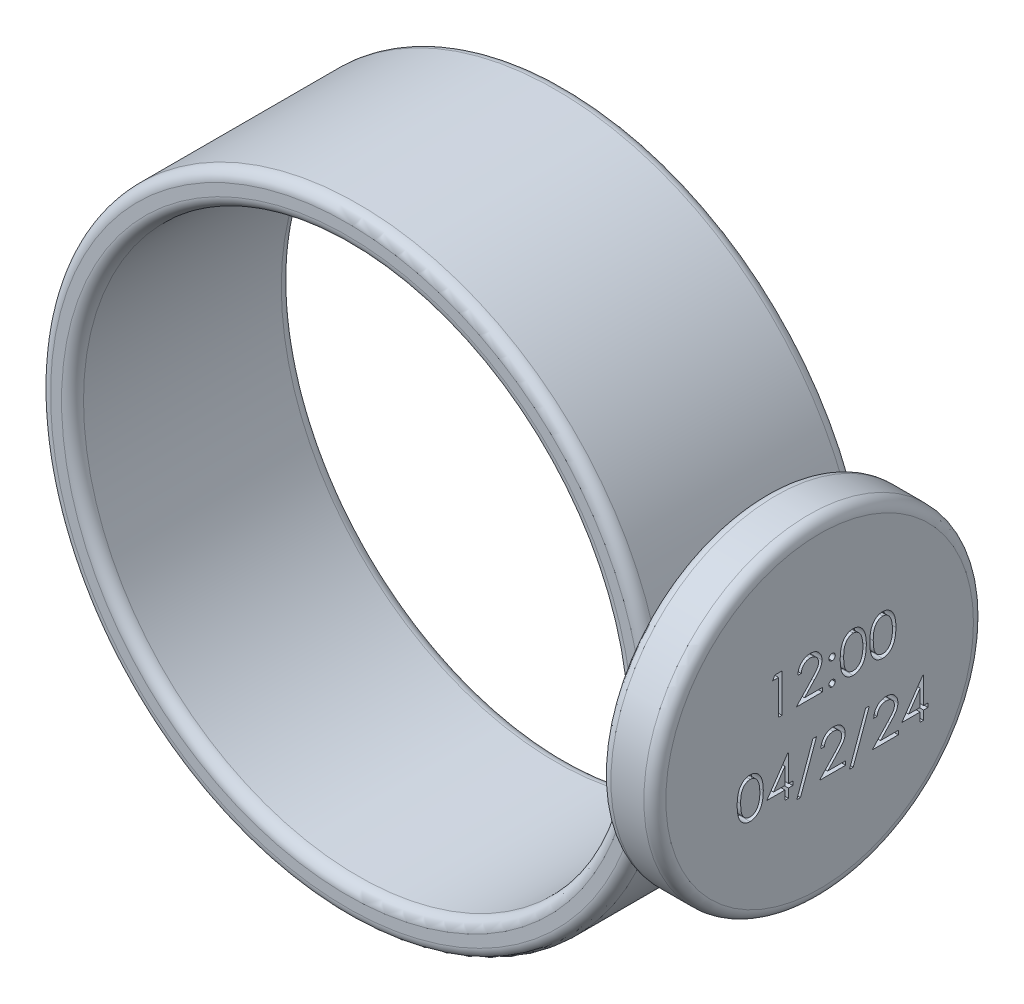
from build123d import *

# Parameters (mm, degrees)
SKETCH1_R           = 28
SKETCH1_R_2         = 25
BOSS_EXTRUDE1_DEPTH = 20
SKETCH2_R           = 15
BOSS_EXTRUDE2_DEPTH = 5
FILLET1_R           = 1
FILLET5_R           = 1
CUT_EXTRUDE3_DEPTH  = 1


with BuildPart() as part:
    # Sketch1 → Boss-Extrude1 (new body)
    with BuildSketch(Plane.XY):
        Circle(SKETCH1_R)
        Circle(SKETCH1_R_2, mode=Mode.SUBTRACT)
    extrude(amount=BOSS_EXTRUDE1_DEPTH)

    # Fillet5
    fillet5_edges = [part.edges().sort_by_distance(p)[0] for p in [
        (-28, 0, 0),
        (-28, 0, 20),
        (-25, 0, 0),
        (-25, 0, 20),
    ]]
    fillet(fillet5_edges, radius=FILLET5_R)


with BuildPart() as body_2:
    # Sketch2 → Boss-Extrude2 (new body)
    with BuildSketch(Plane(origin=(28, 0, 0), x_dir=(0, 0, -1), z_dir=(1, 0, 0))):
        with Locations((-10, 0)):
            Circle(SKETCH2_R)
    extrude(amount=BOSS_EXTRUDE2_DEPTH)

    # Fillet1
    fillet1_edges = [body_2.edges().sort_by_distance(p)[0] for p in [
        (28, 0, 25),
        (33, 0, 25),
    ]]
    fillet(fillet1_edges, radius=FILLET1_R)

    # Sketch5 → Cut-Extrude3 (cut)
    with BuildSketch(Plane(origin=(33, 0, 0), x_dir=(0, 0, -1), z_dir=(1, 0, 0))):
        Polygon((-14.07079668, 4.898543841), (-13.423661263, 4.898543841), (-13.423661263, 1.398543841), (-13.737763827, 1.398543841), (-13.737763827, 4.539569482), (-14.276225365, 4.539569482), align=None)
        with BuildLine():
            Line((-11.673661263, 3.821620764), (-11.987763827, 3.821620764))
            add(Edge.make_bspline(
                [(-11.987763827, 3.821620764), (-11.985716674, 3.863291652), (-11.98169612, 3.945132167), (-11.962867831, 4.064456073), (-11.935926954, 4.178510872), (-11.897835499, 4.286380786), (-11.850529222, 4.389019593), (-11.793799194, 4.486019609), (-11.726605344, 4.577010797), (-11.65039861, 4.661149641), (-11.567629971, 4.738337212), (-11.478324031, 4.804992454), (-11.384479004, 4.861310126), (-11.286379605, 4.908391368), (-11.182919041, 4.943731213), (-11.075036184, 4.969952853), (-10.962257047, 4.985729199), (-10.885417025, 4.987424984), (-10.846337545, 4.988287431)],
                knots=[0, 0, 0, 0, 1.10065271, 2.161652631, 3.183658789, 4.190468796, 5.17591951, 6.163126047, 7.15150782, 8.156236427, 9.156009102, 10.134482811, 11.092018607, 12.041330605, 13.001268258, 13.972401359, 14.968799086, 16, 16, 16, 16], degree=3))
            add(Edge.make_bspline(
                [(-10.846337545, 4.988287431), (-10.807959471, 4.987388975), (-10.732547926, 4.98562354), (-10.622485912, 4.97046251), (-10.517708617, 4.946716919), (-10.418420851, 4.913401503), (-10.325414786, 4.868617075), (-10.237991742, 4.814819536), (-10.155110931, 4.752599705), (-10.080504147, 4.679345892), (-10.011996068, 4.601143507), (-9.952893813, 4.517655604), (-9.902280649, 4.431426318), (-9.86009297, 4.341798116), (-9.829036831, 4.247927088), (-9.805458623, 4.151179885), (-9.792131209, 4.050555074), (-9.790085785, 3.982448518), (-9.789045878, 3.947822687)],
                knots=[0, 0, 0, 0, 1.111607364, 2.184268762, 3.212621178, 4.221274766, 5.211760367, 6.196651075, 7.1921475, 8.207485113, 9.220403448, 10.201281604, 11.166441695, 12.114753415, 13.065576456, 14.026450734, 14.996634279, 16, 16, 16, 16], degree=3))
            add(Edge.make_bspline(
                [(-9.789045878, 3.947822687), (-9.790739141, 3.899074853), (-9.794095952, 3.802434639), (-9.822810329, 3.660419776), (-9.86765684, 3.522826357), (-9.921654197, 3.412089055), (-9.976126641, 3.322855561), (-10.025214149, 3.249386857), (-10.08267896, 3.170281388), (-10.149357458, 3.085804051), (-10.22387033, 2.995293146), (-10.306892493, 2.89880335), (-10.399015975, 2.79733158), (-10.463674476, 2.728025979), (-10.497178891, 2.692113553)],
                knots=[0, 0, 0, 0, 1.184426356, 2.348067706, 3.509069118, 4.696110526, 5.333549288, 6.050745305, 6.844228056, 7.710549037, 8.667450064, 9.695053472, 10.805634456, 12, 12, 12, 12], degree=3))
            Line((-10.497178891, 2.692113553), (-11.372880013, 1.7575182))
            Line((-11.372880013, 1.7575182), (-9.744174083, 1.7575182))
            Line((-9.744174083, 1.7575182), (-9.744174083, 1.398543841))
            Line((-9.744174083, 1.398543841), (-12.122379212, 1.398543841))
            Line((-12.122379212, 1.398543841), (-10.765007417, 2.847061469))
            add(Edge.make_bspline(
                [(-10.765007417, 2.847061469), (-10.73195953, 2.881559776), (-10.668481303, 2.947823963), (-10.578698726, 3.044566923), (-10.498059738, 3.134316464), (-10.426042345, 3.216903012), (-10.36420884, 3.29353458), (-10.309336608, 3.361729283), (-10.265371017, 3.424483734), (-10.217655621, 3.497224348), (-10.17144164, 3.586036665), (-10.131729284, 3.694570354), (-10.107514435, 3.806297607), (-10.1046096, 3.881799644), (-10.103148442, 3.919777816)],
                knots=[0, 0, 0, 0, 1.329631726, 2.553950428, 3.673215718, 4.687767853, 5.603093632, 6.413772471, 7.123043292, 7.734684054, 8.834405432, 9.900288307, 10.943827018, 12, 12, 12, 12], degree=3))
            add(Edge.make_bspline(
                [(-10.103148442, 3.919777816), (-10.103784185, 3.943659214), (-10.105037111, 3.990724864), (-10.116094808, 4.059730623), (-10.132805314, 4.126295437), (-10.156750572, 4.190624056), (-10.188357312, 4.252069708), (-10.226830692, 4.310707189), (-10.271220756, 4.367396154), (-10.322572025, 4.420549452), (-10.378983545, 4.469230657), (-10.438577794, 4.512354743), (-10.501627899, 4.548393854), (-10.567868021, 4.577937351), (-10.63711349, 4.601112732), (-10.709498235, 4.617171311), (-10.784822252, 4.627253795), (-10.836255747, 4.628617967), (-10.862463346, 4.629313072)],
                knots=[0, 0, 0, 0, 0.991446411, 1.95395049, 2.89581595, 3.838931463, 4.798493298, 5.75982156, 6.748411868, 7.785213223, 8.824556874, 9.840280684, 10.836137867, 11.835679398, 12.848801643, 13.863922112, 14.911575587, 16, 16, 16, 16], degree=3))
            add(Edge.make_bspline(
                [(-10.862463346, 4.629313072), (-10.889834179, 4.62859804), (-10.943585975, 4.627193834), (-11.022505008, 4.61737117), (-11.097790786, 4.60042533), (-11.169632689, 4.577248656), (-11.238152274, 4.547790107), (-11.303016318, 4.511098362), (-11.364079208, 4.467314869), (-11.421455731, 4.417674313), (-11.47431971, 4.362406711), (-11.520766586, 4.300796748), (-11.5613506, 4.233969333), (-11.596759834, 4.162104782), (-11.625515524, 4.084551003), (-11.647488674, 4.001583298), (-11.664875521, 3.913561916), (-11.670684041, 3.852776831), (-11.673661263, 3.821620764)],
                knots=[0, 0, 0, 0, 1.031018746, 2.02475058, 2.990194455, 3.934040569, 4.864654155, 5.795059489, 6.735614925, 7.690564532, 8.649604399, 9.611025574, 10.590972636, 11.591080095, 12.624614302, 13.701020113, 14.821632451, 16, 16, 16, 16], degree=3))
        make_face()
        with BuildLine():
            add(Edge.make_bspline(
                [(-8.869174083, 4.001107944), (-8.849683871, 3.999949777), (-8.811475589, 3.997679327), (-8.756236461, 3.982102653), (-8.706241801, 3.954443993), (-8.661709556, 3.917581214), (-8.62500308, 3.872885551), (-8.596358727, 3.823289642), (-8.580917742, 3.76758805), (-8.57866383, 3.729158375), (-8.577507417, 3.709441277)],
                knots=[0, 0, 0, 0, 1.020151414, 1.999887582, 2.974338812, 3.990962822, 5.007586832, 5.987933904, 6.967670073, 8, 8, 8, 8], degree=3))
            add(Edge.make_bspline(
                [(-8.577507417, 3.709441277), (-8.57866383, 3.68972418), (-8.580917742, 3.651294505), (-8.596358727, 3.595592912), (-8.62500308, 3.545997003), (-8.661709556, 3.50130134), (-8.706241801, 3.464438562), (-8.756236461, 3.436779901), (-8.811475589, 3.421203228), (-8.849683871, 3.418932777), (-8.869174083, 3.41777461)],
                knots=[0, 0, 0, 0, 1.032329927, 2.012066096, 2.992413168, 4.009037178, 5.025661188, 6.000112418, 6.979848586, 8, 8, 8, 8], degree=3))
            add(Edge.make_bspline(
                [(-8.869174083, 3.41777461), (-8.888677785, 3.418894506), (-8.926687724, 3.421077023), (-8.981727264, 3.437117435), (-9.032023469, 3.464182228), (-9.076547765, 3.501369531), (-9.11355316, 3.545766111), (-9.140929372, 3.59593455), (-9.157705032, 3.651133658), (-9.159778651, 3.689691898), (-9.16084075, 3.709441277)],
                knots=[0, 0, 0, 0, 1.020591893, 1.988988293, 2.974634352, 3.991697318, 5.008760285, 5.983632262, 6.967224335, 8, 8, 8, 8], degree=3))
            add(Edge.make_bspline(
                [(-9.16084075, 3.709441277), (-9.159739929, 3.72871909), (-9.157565378, 3.766800281), (-9.14092151, 3.821533677), (-9.113587869, 3.871759072), (-9.076313445, 3.916050593), (-9.032292504, 3.954132893), (-8.981567818, 3.980822161), (-8.92682963, 3.998038024), (-8.888703362, 4.00006809), (-8.869174083, 4.001107944)],
                knots=[0, 0, 0, 0, 1.010056097, 1.99525427, 2.971718109, 3.990441831, 5.01702829, 6.004283803, 6.977741589, 8, 8, 8, 8], degree=3))
        make_face()
        with BuildLine():
            add(Edge.make_bspline(
                [(-8.869174083, 1.93700538), (-8.849683871, 1.935847213), (-8.811475589, 1.933576763), (-8.756236461, 1.918000089), (-8.706241801, 1.890341428), (-8.661709556, 1.85347865), (-8.62500308, 1.808782987), (-8.596358727, 1.759187078), (-8.580917742, 1.703485486), (-8.57866383, 1.665055811), (-8.577507417, 1.645338713)],
                knots=[0, 0, 0, 0, 1.020151414, 1.999887582, 2.974338812, 3.990962822, 5.007586832, 5.987933904, 6.967670073, 8, 8, 8, 8], degree=3))
            add(Edge.make_bspline(
                [(-8.577507417, 1.645338713), (-8.578703017, 1.626095383), (-8.581060725, 1.58814782), (-8.596323333, 1.532866357), (-8.625221383, 1.483239453), (-8.661456376, 1.437937314), (-8.706252809, 1.400996444), (-8.756354656, 1.373573099), (-8.811345914, 1.356881119), (-8.849662237, 1.354754822), (-8.869174083, 1.353672046)],
                knots=[0, 0, 0, 0, 1.009421747, 1.99056486, 2.972319754, 3.999869655, 5.017953583, 5.993804169, 6.978383603, 8, 8, 8, 8], degree=3))
            add(Edge.make_bspline(
                [(-8.869174083, 1.353672046), (-8.888699989, 1.354715644), (-8.926819672, 1.356753019), (-8.981605666, 1.373915825), (-9.032012634, 1.400739285), (-9.076800346, 1.438006195), (-9.113338818, 1.483006338), (-9.140964201, 1.533208134), (-9.15755435, 1.587989572), (-9.159736222, 1.626064215), (-9.16084075, 1.645338713)],
                knots=[0, 0, 0, 0, 1.022052826, 1.995314843, 2.982371812, 4.00089066, 5.028879526, 6.005146991, 6.990147033, 8, 8, 8, 8], degree=3))
            add(Edge.make_bspline(
                [(-9.16084075, 1.645338713), (-9.159778651, 1.665088093), (-9.157705032, 1.703646333), (-9.140929372, 1.75884544), (-9.11355316, 1.809013879), (-9.076547765, 1.85341046), (-9.032023469, 1.890597762), (-8.981727264, 1.917662555), (-8.926687724, 1.933702968), (-8.888677785, 1.935885484), (-8.869174083, 1.93700538)],
                knots=[0, 0, 0, 0, 1.032775665, 2.016367738, 2.991239715, 4.008302682, 5.025365648, 6.011011707, 6.979408107, 8, 8, 8, 8], degree=3))
        make_face()
        with BuildLine():
            add(Edge.make_bspline(
                [(-8.128789468, 3.147141598), (-8.12846145, 3.203238985), (-8.12782427, 3.31220897), (-8.120735849, 3.470993612), (-8.108960507, 3.619953901), (-8.092823134, 3.759096967), (-8.073185154, 3.888458731), (-8.046969667, 4.007693488), (-8.017156864, 4.117353095), (-7.982604419, 4.217795144), (-7.94361663, 4.310372847), (-7.901182369, 4.396798048), (-7.853617574, 4.47693998), (-7.803640661, 4.552077771), (-7.74922859, 4.620981465), (-7.691929799, 4.684624128), (-7.629507923, 4.741534878), (-7.564084915, 4.793381181), (-7.49506845, 4.838830652), (-7.424425784, 4.878863391), (-7.351670678, 4.913063258), (-7.276604496, 4.939953694), (-7.199901938, 4.962164541), (-7.121294871, 4.977353489), (-7.040653507, 4.986910397), (-6.986222072, 4.987824065), (-6.958617192, 4.988287431)],
                knots=[0, 0, 0, 0, 1.646270934, 3.197905019, 4.663502075, 6.030701355, 7.308322542, 8.50163776, 9.611534131, 10.641858119, 11.616356847, 12.558055219, 13.465016945, 14.349605745, 15.204443733, 16.039544428, 16.859896111, 17.680448484, 18.487036065, 19.28249412, 20.06191084, 20.843045899, 21.620316918, 22.403196591, 23.190181807, 24, 24, 24, 24], degree=3))
            add(Edge.make_bspline(
                [(-6.958617192, 4.988287431), (-6.930781714, 4.987799616), (-6.875425705, 4.986829505), (-6.79358533, 4.977505562), (-6.713635648, 4.962034439), (-6.635917509, 4.940113465), (-6.559792523, 4.912917788), (-6.485856115, 4.878830671), (-6.413649034, 4.839151804), (-6.344318746, 4.792527926), (-6.277104131, 4.74054565), (-6.213656168, 4.681782981), (-6.153969082, 4.616833262), (-6.097293776, 4.546391398), (-6.045238179, 4.469106313), (-5.995664747, 4.386322203), (-5.951292711, 4.296591339), (-5.908558036, 4.201410871), (-5.871671049, 4.098147212), (-5.838404804, 3.987382452), (-5.811525835, 3.867808265), (-5.789136563, 3.740052019), (-5.771791667, 3.603644536), (-5.759159025, 3.458878221), (-5.75248594, 3.30565783), (-5.751229239, 3.200899981), (-5.75058434, 3.147141598)],
                knots=[0, 0, 0, 0, 0.810914788, 1.612654377, 2.396697861, 3.181598691, 3.963628158, 4.749916497, 5.551656086, 6.361998678, 7.18212741, 8.025565596, 8.878627764, 9.750805457, 10.657531673, 11.591944965, 12.560506719, 13.57287815, 14.630710178, 15.753379473, 16.941251878, 18.199788006, 19.531962791, 20.947069417, 22.433333509, 24, 24, 24, 24], degree=3))
            add(Edge.make_bspline(
                [(-5.75058434, 3.147141598), (-5.751235924, 3.09361769), (-5.75250551, 2.989328538), (-5.759084217, 2.836797563), (-5.772042848, 2.692799519), (-5.788252837, 2.556989057), (-5.8107038, 2.429931438), (-5.838308966, 2.311186989), (-5.868959289, 2.200242918), (-5.906794083, 2.098008106), (-5.948204793, 2.003056383), (-5.993259989, 1.914389235), (-6.041529815, 1.831222942), (-6.09411856, 1.754223195), (-6.150171974, 1.682844538), (-6.210889762, 1.618346916), (-6.274560347, 1.559176244), (-6.341972763, 1.506524616), (-6.412384314, 1.460439812), (-6.484343391, 1.419225961), (-6.559126775, 1.385993266), (-6.635039727, 1.357458225), (-6.713168094, 1.335657773), (-6.793414484, 1.320583918), (-6.87537072, 1.310012069), (-6.930772285, 1.309205589), (-6.958617192, 1.308800252)],
                knots=[0, 0, 0, 0, 1.561518951, 3.042555995, 4.452378317, 5.7783523, 7.031515105, 8.214008947, 9.334062868, 10.386615937, 11.391082383, 12.354592575, 13.286541444, 14.194233754, 15.072674879, 15.931287219, 16.775624067, 17.606195743, 18.42308326, 19.229000347, 20.022332153, 20.807536673, 21.593273796, 22.3848459, 23.188221202, 24, 24, 24, 24], degree=3))
            add(Edge.make_bspline(
                [(-6.958617192, 1.308800252), (-6.986221306, 1.309266607), (-7.040651231, 1.310186169), (-7.121303657, 1.3196999), (-7.1995861, 1.334995404), (-7.275884854, 1.356412008), (-7.350591369, 1.382626844), (-7.422687656, 1.416780528), (-7.492975339, 1.456114597), (-7.561266896, 1.500910018), (-7.626279057, 1.552231701), (-7.688377662, 1.60899599), (-7.746002681, 1.672619401), (-7.799636777, 1.742097324), (-7.850610865, 1.816790567), (-7.897500238, 1.89771894), (-7.940871092, 1.98456155), (-7.980514583, 2.077879461), (-8.015663246, 2.179034389), (-8.046710954, 2.289183567), (-8.071225112, 2.409299203), (-8.092208067, 2.53841657), (-8.10913245, 2.677090501), (-8.120686776, 2.825396279), (-8.127828091, 2.983241488), (-8.128463161, 3.091511262), (-8.128789468, 3.147141598)],
                knots=[0, 0, 0, 0, 0.810891512, 1.598919785, 2.382837074, 3.152667961, 3.926044502, 4.706494248, 5.493654104, 6.291793342, 7.103789334, 7.925228297, 8.761435821, 9.622817696, 10.50288917, 11.416980706, 12.369136599, 13.353924996, 14.394355917, 15.514179734, 16.714354668, 17.994756427, 19.357759367, 20.818452758, 22.365282078, 24, 24, 24, 24], degree=3))
        make_face()
        with BuildLine():
            add(Edge.make_bspline(
                [(-7.814686904, 3.148543841), (-7.814567457, 3.101795142), (-7.814335634, 3.011065098), (-7.808279433, 2.879221837), (-7.800029201, 2.756251508), (-7.789387904, 2.641997971), (-7.773584955, 2.536847959), (-7.755878167, 2.440078276), (-7.734330078, 2.352201039), (-7.70883506, 2.272613228), (-7.679795963, 2.19996416), (-7.648090099, 2.132362944), (-7.614029376, 2.069011008), (-7.575910226, 2.0104774), (-7.534395163, 1.956571236), (-7.490421904, 1.906338403), (-7.442349319, 1.861541422), (-7.375845577, 1.807814567), (-7.288049102, 1.752295433), (-7.177428647, 1.703949343), (-7.063760196, 1.673566887), (-6.986608946, 1.669703131), (-6.948100365, 1.66777461)],
                knots=[0, 0, 0, 0, 1.459021318, 2.831673884, 4.118529203, 5.306027144, 6.411944654, 7.436330062, 8.375795394, 9.233974572, 10.042671642, 10.816086306, 11.563610507, 12.285937304, 12.993564865, 13.685989202, 14.367179055, 15.041617293, 16.353048772, 17.594441528, 18.799311195, 20, 20, 20, 20], degree=3))
            add(Edge.make_bspline(
                [(-6.948100365, 1.66777461), (-6.909342694, 1.669372391), (-6.831907371, 1.672564654), (-6.718773575, 1.703363391), (-6.608943305, 1.749832931), (-6.522871365, 1.804780436), (-6.457388822, 1.857108766), (-6.410471832, 1.901723414), (-6.367409783, 1.951679281), (-6.326567708, 2.005578577), (-6.289108633, 2.064451062), (-6.255045495, 2.128013637), (-6.223962147, 2.196442815), (-6.206253101, 2.244212554), (-6.197198923, 2.268635989)],
                knots=[0, 0, 0, 0, 1.353760809, 2.704726607, 4.075137775, 5.516104923, 6.260822281, 7.007110065, 7.778089737, 8.566572457, 9.372053459, 10.217411131, 11.088608312, 12, 12, 12, 12], degree=3))
            add(Edge.make_bspline(
                [(-6.197198923, 2.268635989), (-6.186647155, 2.299865728), (-6.165222542, 2.363275492), (-6.137610767, 2.461639144), (-6.115865368, 2.564841908), (-6.096302002, 2.672267025), (-6.082948946, 2.784706726), (-6.072201133, 2.90181311), (-6.065870446, 3.023674472), (-6.065085695, 3.106469464), (-6.064686904, 3.148543841)],
                knots=[0, 0, 0, 0, 0.884706709, 1.796334032, 2.740027952, 3.714592787, 4.726048262, 5.777819803, 6.87074269, 8, 8, 8, 8], degree=3))
            add(Edge.make_bspline(
                [(-6.064686904, 3.148543841), (-6.065237093, 3.190611414), (-6.066313381, 3.272904579), (-6.070427369, 3.393422759), (-6.081050943, 3.50789052), (-6.092850062, 3.616800993), (-6.110247283, 3.719551296), (-6.12900509, 3.817001601), (-6.154206302, 3.907944626), (-6.181126077, 3.993804207), (-6.211936473, 4.073604862), (-6.245852207, 4.147718648), (-6.282073966, 4.216503373), (-6.321416206, 4.279770314), (-6.363411889, 4.337802857), (-6.409169438, 4.389437452), (-6.456873811, 4.43627442), (-6.523690997, 4.489736989), (-6.611165287, 4.544248685), (-6.720010934, 4.594414445), (-6.833281579, 4.623222737), (-6.909855033, 4.627284424), (-6.948100365, 4.629313072)],
                knots=[0, 0, 0, 0, 1.31362396, 2.569729283, 3.763502607, 4.902122613, 5.988968491, 7.01645872, 7.998833611, 8.933434873, 9.825090667, 10.667526885, 11.477055099, 12.250526234, 12.991942729, 13.710640831, 14.402115721, 15.076753259, 16.378508321, 17.609869233, 18.806226677, 20, 20, 20, 20], degree=3))
            add(Edge.make_bspline(
                [(-6.948100365, 4.629313072), (-6.986810958, 4.627281625), (-7.064302663, 4.623215031), (-7.178750618, 4.594521778), (-7.28845497, 4.544508812), (-7.375697944, 4.489556439), (-7.442561731, 4.437218128), (-7.489644424, 4.391831674), (-7.533790596, 4.342185419), (-7.574458296, 4.287783505), (-7.61254758, 4.229318137), (-7.647528592, 4.166329373), (-7.679045922, 4.098498008), (-7.708130458, 4.025881573), (-7.733703246, 3.946300628), (-7.754797209, 3.858531635), (-7.774284262, 3.762069743), (-7.788079531, 3.656350235), (-7.800343287, 3.542068082), (-7.808224635, 3.418790764), (-7.814355893, 3.286726383), (-7.814574357, 3.195527225), (-7.814686904, 3.148543841)],
                knots=[0, 0, 0, 0, 1.207732386, 2.417664972, 3.655092373, 4.956220595, 5.625982001, 6.301752483, 6.994047911, 7.697131622, 8.419323945, 9.170223765, 9.943494443, 10.752040957, 11.610060368, 12.549350801, 13.567764191, 14.679664412, 15.874934091, 17.154273443, 18.533957287, 20, 20, 20, 20], degree=3))
        make_face(mode=Mode.SUBTRACT)
        with BuildLine():
            add(Edge.make_bspline(
                [(-5.436481776, 3.147141598), (-5.436153758, 3.203238985), (-5.435516578, 3.31220897), (-5.428428157, 3.470993612), (-5.416652814, 3.619953901), (-5.400515441, 3.759096967), (-5.380877461, 3.888458731), (-5.354661975, 4.007693488), (-5.324849172, 4.117353095), (-5.290296726, 4.217795144), (-5.251308937, 4.310372847), (-5.208874676, 4.396798048), (-5.161309882, 4.47693998), (-5.111332969, 4.552077771), (-5.056920897, 4.620981465), (-4.999622107, 4.684624128), (-4.937200231, 4.741534878), (-4.871777222, 4.793381181), (-4.802760758, 4.838830652), (-4.732118092, 4.878863391), (-4.659362986, 4.913063258), (-4.584296803, 4.939953694), (-4.507594245, 4.962164541), (-4.428987179, 4.977353489), (-4.348345815, 4.986910397), (-4.29391438, 4.987824065), (-4.2663095, 4.988287431)],
                knots=[0, 0, 0, 0, 1.646270934, 3.197905019, 4.663502075, 6.030701355, 7.308322542, 8.50163776, 9.611534131, 10.641858119, 11.616356847, 12.558055219, 13.465016945, 14.349605745, 15.204443733, 16.039544428, 16.859896111, 17.680448484, 18.487036065, 19.28249412, 20.06191084, 20.843045899, 21.620316918, 22.403196591, 23.190181807, 24, 24, 24, 24], degree=3))
            add(Edge.make_bspline(
                [(-4.2663095, 4.988287431), (-4.238474022, 4.987799616), (-4.183118013, 4.986829505), (-4.101277637, 4.977505562), (-4.021327956, 4.962034439), (-3.943609817, 4.940113465), (-3.867484831, 4.912917788), (-3.793548423, 4.878830671), (-3.721341341, 4.839151804), (-3.652011054, 4.792527926), (-3.584796438, 4.74054565), (-3.521348475, 4.681782981), (-3.46166139, 4.616833262), (-3.404986084, 4.546391398), (-3.352930487, 4.469106313), (-3.303357055, 4.386322203), (-3.258985019, 4.296591339), (-3.216250344, 4.201410871), (-3.179363357, 4.098147212), (-3.146097112, 3.987382452), (-3.119218143, 3.867808265), (-3.096828871, 3.740052019), (-3.079483975, 3.603644536), (-3.066851333, 3.458878221), (-3.060178248, 3.30565783), (-3.058921546, 3.200899981), (-3.058276648, 3.147141598)],
                knots=[0, 0, 0, 0, 0.810914788, 1.612654377, 2.396697861, 3.181598691, 3.963628158, 4.749916497, 5.551656086, 6.361998678, 7.18212741, 8.025565596, 8.878627764, 9.750805457, 10.657531673, 11.591944965, 12.560506719, 13.57287815, 14.630710178, 15.753379473, 16.941251878, 18.199788006, 19.531962791, 20.947069417, 22.433333509, 24, 24, 24, 24], degree=3))
            add(Edge.make_bspline(
                [(-3.058276648, 3.147141598), (-3.058928232, 3.09361769), (-3.060197818, 2.989328538), (-3.066776525, 2.836797563), (-3.079735156, 2.692799519), (-3.095945144, 2.556989057), (-3.118396107, 2.429931438), (-3.146001273, 2.311186989), (-3.176651596, 2.200242918), (-3.21448639, 2.098008106), (-3.255897101, 2.003056383), (-3.300952297, 1.914389235), (-3.349222123, 1.831222942), (-3.401810868, 1.754223195), (-3.457864281, 1.682844538), (-3.51858207, 1.618346916), (-3.582252655, 1.559176244), (-3.649665071, 1.506524616), (-3.720076622, 1.460439812), (-3.792035699, 1.419225961), (-3.866819082, 1.385993266), (-3.942732035, 1.357458225), (-4.020860401, 1.335657773), (-4.101106792, 1.320583918), (-4.183063028, 1.310012069), (-4.238464593, 1.309205589), (-4.2663095, 1.308800252)],
                knots=[0, 0, 0, 0, 1.561518951, 3.042555995, 4.452378317, 5.7783523, 7.031515105, 8.214008947, 9.334062868, 10.386615937, 11.391082383, 12.354592575, 13.286541444, 14.194233754, 15.072674879, 15.931287219, 16.775624067, 17.606195743, 18.42308326, 19.229000347, 20.022332153, 20.807536673, 21.593273796, 22.3848459, 23.188221202, 24, 24, 24, 24], degree=3))
            add(Edge.make_bspline(
                [(-4.2663095, 1.308800252), (-4.293913614, 1.309266607), (-4.348343539, 1.310186169), (-4.428995964, 1.3196999), (-4.507278408, 1.334995404), (-4.583577162, 1.356412008), (-4.658283677, 1.382626844), (-4.730379963, 1.416780528), (-4.800667647, 1.456114597), (-4.868959203, 1.500910018), (-4.933971364, 1.552231701), (-4.99606997, 1.60899599), (-5.053694989, 1.672619401), (-5.107329084, 1.742097324), (-5.158303172, 1.816790567), (-5.205192546, 1.89771894), (-5.2485634, 1.98456155), (-5.288206891, 2.077879461), (-5.323355554, 2.179034389), (-5.354403262, 2.289183567), (-5.37891742, 2.409299203), (-5.399900375, 2.53841657), (-5.416824758, 2.677090501), (-5.428379083, 2.825396279), (-5.435520398, 2.983241488), (-5.436155469, 3.091511262), (-5.436481776, 3.147141598)],
                knots=[0, 0, 0, 0, 0.810891512, 1.598919785, 2.382837074, 3.152667961, 3.926044502, 4.706494248, 5.493654104, 6.291793342, 7.103789334, 7.925228297, 8.761435821, 9.622817696, 10.50288917, 11.416980706, 12.369136599, 13.353924996, 14.394355917, 15.514179734, 16.714354668, 17.994756427, 19.357759367, 20.818452758, 22.365282078, 24, 24, 24, 24], degree=3))
        make_face()
        with BuildLine():
            add(Edge.make_bspline(
                [(-5.122379212, 3.148543841), (-5.122259765, 3.101795142), (-5.122027941, 3.011065098), (-5.115971741, 2.879221837), (-5.107721509, 2.756251508), (-5.097080211, 2.641997971), (-5.081277263, 2.536847959), (-5.063570475, 2.440078276), (-5.042022386, 2.352201039), (-5.016527368, 2.272613228), (-4.987488271, 2.19996416), (-4.955782407, 2.132362944), (-4.921721684, 2.069011008), (-4.883602534, 2.0104774), (-4.84208747, 1.956571236), (-4.798114211, 1.906338403), (-4.750041627, 1.861541422), (-4.683537884, 1.807814567), (-4.59574141, 1.752295433), (-4.485120955, 1.703949343), (-4.371452504, 1.673566887), (-4.294301254, 1.669703131), (-4.255792673, 1.66777461)],
                knots=[0, 0, 0, 0, 1.459021318, 2.831673884, 4.118529203, 5.306027144, 6.411944654, 7.436330062, 8.375795394, 9.233974572, 10.042671642, 10.816086306, 11.563610507, 12.285937304, 12.993564865, 13.685989202, 14.367179055, 15.041617293, 16.353048772, 17.594441528, 18.799311195, 20, 20, 20, 20], degree=3))
            add(Edge.make_bspline(
                [(-4.255792673, 1.66777461), (-4.217035002, 1.669372391), (-4.139599678, 1.672564654), (-4.026465883, 1.703363391), (-3.916635613, 1.749832931), (-3.830563673, 1.804780436), (-3.765081129, 1.857108766), (-3.718164139, 1.901723414), (-3.675102091, 1.951679281), (-3.634260016, 2.005578577), (-3.59680094, 2.064451062), (-3.562737803, 2.128013637), (-3.531654455, 2.196442815), (-3.513945409, 2.244212554), (-3.504891231, 2.268635989)],
                knots=[0, 0, 0, 0, 1.353760809, 2.704726607, 4.075137775, 5.516104923, 6.260822281, 7.007110065, 7.778089737, 8.566572457, 9.372053459, 10.217411131, 11.088608312, 12, 12, 12, 12], degree=3))
            add(Edge.make_bspline(
                [(-3.504891231, 2.268635989), (-3.494339463, 2.299865728), (-3.472914849, 2.363275492), (-3.445303075, 2.461639144), (-3.423557676, 2.564841908), (-3.40399431, 2.672267025), (-3.390641254, 2.784706726), (-3.379893441, 2.90181311), (-3.373562754, 3.023674472), (-3.372778003, 3.106469464), (-3.372379212, 3.148543841)],
                knots=[0, 0, 0, 0, 0.884706709, 1.796334032, 2.740027952, 3.714592787, 4.726048262, 5.777819803, 6.87074269, 8, 8, 8, 8], degree=3))
            add(Edge.make_bspline(
                [(-3.372379212, 3.148543841), (-3.372929401, 3.190611414), (-3.374005689, 3.272904579), (-3.378119676, 3.393422759), (-3.388743251, 3.50789052), (-3.40054237, 3.616800993), (-3.417939591, 3.719551296), (-3.436697398, 3.817001601), (-3.46189861, 3.907944626), (-3.488818385, 3.993804207), (-3.51962878, 4.073604862), (-3.553544515, 4.147718648), (-3.589766273, 4.216503373), (-3.629108514, 4.279770314), (-3.671104197, 4.337802857), (-3.716861746, 4.389437452), (-3.764566119, 4.43627442), (-3.831383305, 4.489736989), (-3.918857595, 4.544248685), (-4.027703242, 4.594414445), (-4.140973886, 4.623222737), (-4.21754734, 4.627284424), (-4.255792673, 4.629313072)],
                knots=[0, 0, 0, 0, 1.31362396, 2.569729283, 3.763502607, 4.902122613, 5.988968491, 7.01645872, 7.998833611, 8.933434873, 9.825090667, 10.667526885, 11.477055099, 12.250526234, 12.991942729, 13.710640831, 14.402115721, 15.076753259, 16.378508321, 17.609869233, 18.806226677, 20, 20, 20, 20], degree=3))
            add(Edge.make_bspline(
                [(-4.255792673, 4.629313072), (-4.294503265, 4.627281625), (-4.371994971, 4.623215031), (-4.486442926, 4.594521778), (-4.596147277, 4.544508812), (-4.683390252, 4.489556439), (-4.750254038, 4.437218128), (-4.797336732, 4.391831674), (-4.841482904, 4.342185419), (-4.882150604, 4.287783505), (-4.920239887, 4.229318137), (-4.9552209, 4.166329373), (-4.98673823, 4.098498008), (-5.015822766, 4.025881573), (-5.041395554, 3.946300628), (-5.062489517, 3.858531635), (-5.08197657, 3.762069743), (-5.095771839, 3.656350235), (-5.108035595, 3.542068082), (-5.115916943, 3.418790764), (-5.1220482, 3.286726383), (-5.122266665, 3.195527225), (-5.122379212, 3.148543841)],
                knots=[0, 0, 0, 0, 1.207732386, 2.417664972, 3.655092373, 4.956220595, 5.625982001, 6.301752483, 6.994047911, 7.697131622, 8.419323945, 9.170223765, 9.943494443, 10.752040957, 11.610060368, 12.549350801, 13.567764191, 14.679664412, 15.874934091, 17.154273443, 18.533957287, 20, 20, 20, 20], degree=3))
        make_face(mode=Mode.SUBTRACT)
        with BuildLine():
            add(Edge.make_bspline(
                [(-17.506994596, -3.686191736), (-17.506666578, -3.630094348), (-17.506029398, -3.521124364), (-17.498940977, -3.362339722), (-17.487165635, -3.213379433), (-17.471028262, -3.074236367), (-17.451390282, -2.944874602), (-17.425174795, -2.825639845), (-17.395361993, -2.715980238), (-17.360809547, -2.61553819), (-17.321821758, -2.522960487), (-17.279387497, -2.436535286), (-17.231822703, -2.356393353), (-17.18184579, -2.281255563), (-17.127433718, -2.212351868), (-17.070134928, -2.148709205), (-17.007713051, -2.091798455), (-16.942290043, -2.039952153), (-16.873273579, -1.994502681), (-16.802630912, -1.954469942), (-16.729875807, -1.920270075), (-16.654809624, -1.893379639), (-16.578107066, -1.871168792), (-16.499499999, -1.855979845), (-16.418858635, -1.846422936), (-16.3644272, -1.845509269), (-16.336822321, -1.845045902)],
                knots=[0, 0, 0, 0, 1.646270934, 3.197905019, 4.663502075, 6.030701355, 7.308322542, 8.50163776, 9.611534131, 10.641858119, 11.616356847, 12.558055219, 13.465016945, 14.349605745, 15.204443733, 16.039544428, 16.859896111, 17.680448484, 18.487036065, 19.28249412, 20.06191084, 20.843045899, 21.620316918, 22.403196591, 23.190181807, 24, 24, 24, 24], degree=3))
            add(Edge.make_bspline(
                [(-16.336822321, -1.845045902), (-16.308986842, -1.845533718), (-16.253630833, -1.846503828), (-16.171790458, -1.855827771), (-16.091840776, -1.871298894), (-16.014122638, -1.893219869), (-15.937997651, -1.920415545), (-15.864061243, -1.954502662), (-15.791854162, -1.99418153), (-15.722523874, -2.040805407), (-15.655309259, -2.092787683), (-15.591861296, -2.151550352), (-15.53217421, -2.216500071), (-15.475498905, -2.286941935), (-15.423443307, -2.36422702), (-15.373869875, -2.44701113), (-15.329497839, -2.536741995), (-15.286763164, -2.631922462), (-15.249876177, -2.735186121), (-15.216609932, -2.845950882), (-15.189730964, -2.965525069), (-15.167341691, -3.093281314), (-15.149996795, -3.229688797), (-15.137364153, -3.374455113), (-15.130691068, -3.527675503), (-15.129434367, -3.632433353), (-15.128789468, -3.686191736)],
                knots=[0, 0, 0, 0, 0.810914788, 1.612654377, 2.396697861, 3.181598691, 3.963628158, 4.749916497, 5.551656086, 6.361998678, 7.18212741, 8.025565596, 8.878627764, 9.750805457, 10.657531673, 11.591944965, 12.560506719, 13.57287815, 14.630710178, 15.753379473, 16.941251878, 18.199788006, 19.531962791, 20.947069417, 22.433333509, 24, 24, 24, 24], degree=3))
            add(Edge.make_bspline(
                [(-15.128789468, -3.686191736), (-15.129441053, -3.739715644), (-15.130710638, -3.844004795), (-15.137289345, -3.996535771), (-15.150247976, -4.140533814), (-15.166457965, -4.276344277), (-15.188908928, -4.403401895), (-15.216514094, -4.522146344), (-15.247164417, -4.633090416), (-15.284999211, -4.735325227), (-15.326409921, -4.83027695), (-15.371465117, -4.918944098), (-15.419734944, -5.002110391), (-15.472323689, -5.079110138), (-15.528377102, -5.150488795), (-15.589094891, -5.214986418), (-15.652765476, -5.27415709), (-15.720177891, -5.326808717), (-15.790589443, -5.372893522), (-15.86254852, -5.414107372), (-15.937331903, -5.447340067), (-16.013244856, -5.475875108), (-16.091373222, -5.49767556), (-16.171619612, -5.512749416), (-16.253575848, -5.523321264), (-16.308977413, -5.524127744), (-16.336822321, -5.524533082)],
                knots=[0, 0, 0, 0, 1.561518951, 3.042555995, 4.452378317, 5.7783523, 7.031515105, 8.214008947, 9.334062868, 10.386615937, 11.391082383, 12.354592575, 13.286541444, 14.194233754, 15.072674879, 15.931287219, 16.775624067, 17.606195743, 18.42308326, 19.229000347, 20.022332153, 20.807536673, 21.593273796, 22.3848459, 23.188221202, 24, 24, 24, 24], degree=3))
            add(Edge.make_bspline(
                [(-16.336822321, -5.524533082), (-16.364426435, -5.524066726), (-16.418856359, -5.523147164), (-16.499508785, -5.513633433), (-16.577791228, -5.49833793), (-16.654089982, -5.476921326), (-16.728796497, -5.450706489), (-16.800892784, -5.416552806), (-16.871180468, -5.377218737), (-16.939472024, -5.332423315), (-17.004484185, -5.281101632), (-17.06658279, -5.224337343), (-17.124207809, -5.160713932), (-17.177841905, -5.091236009), (-17.228815993, -5.016542767), (-17.275705366, -4.935614394), (-17.31907622, -4.848771783), (-17.358719711, -4.755453873), (-17.393868375, -4.654298945), (-17.424916083, -4.544149766), (-17.44943024, -4.42403413), (-17.470413195, -4.294916763), (-17.487337579, -4.156242833), (-17.498891904, -4.007937054), (-17.506033219, -3.850091845), (-17.506668289, -3.741822071), (-17.506994596, -3.686191736)],
                knots=[0, 0, 0, 0, 0.810891512, 1.598919785, 2.382837074, 3.152667961, 3.926044502, 4.706494248, 5.493654104, 6.291793342, 7.103789334, 7.925228297, 8.761435821, 9.622817696, 10.50288917, 11.416980706, 12.369136599, 13.353924996, 14.394355917, 15.514179734, 16.714354668, 17.994756427, 19.357759367, 20.818452758, 22.365282078, 24, 24, 24, 24], degree=3))
        make_face()
        with BuildLine():
            add(Edge.make_bspline(
                [(-17.192892032, -3.684789492), (-17.192772585, -3.731538191), (-17.192540762, -3.822268236), (-17.186484561, -3.954111497), (-17.178234329, -4.077081825), (-17.167593032, -4.191335362), (-17.151790083, -4.296485374), (-17.134083296, -4.393255058), (-17.112535206, -4.481132295), (-17.087040188, -4.560720105), (-17.058001091, -4.633369174), (-17.026295228, -4.700970389), (-16.992234505, -4.764322325), (-16.954115354, -4.822855934), (-16.912600291, -4.876762098), (-16.868627032, -4.92699493), (-16.820554448, -4.971791911), (-16.754050705, -5.025518767), (-16.666254231, -5.0810379), (-16.555633775, -5.12938399), (-16.441965324, -5.159766447), (-16.364814074, -5.163630202), (-16.326305494, -5.165558723)],
                knots=[0, 0, 0, 0, 1.459021318, 2.831673884, 4.118529203, 5.306027144, 6.411944654, 7.436330062, 8.375795394, 9.233974572, 10.042671642, 10.816086306, 11.563610507, 12.285937304, 12.993564865, 13.685989202, 14.367179055, 15.041617293, 16.353048772, 17.594441528, 18.799311195, 20, 20, 20, 20], degree=3))
            add(Edge.make_bspline(
                [(-16.326305494, -5.165558723), (-16.287547822, -5.163960942), (-16.210112499, -5.160768679), (-16.096978704, -5.129969942), (-15.987148434, -5.083500402), (-15.901076493, -5.028552897), (-15.83559395, -4.976224568), (-15.78867696, -4.931609919), (-15.745614911, -4.881654052), (-15.704772836, -4.827754756), (-15.667313761, -4.768882272), (-15.633250623, -4.705319697), (-15.602167276, -4.636890519), (-15.58445823, -4.58912078), (-15.575404051, -4.564697345)],
                knots=[0, 0, 0, 0, 1.353760809, 2.704726607, 4.075137775, 5.516104923, 6.260822281, 7.007110065, 7.778089737, 8.566572457, 9.372053459, 10.217411131, 11.088608312, 12, 12, 12, 12], degree=3))
            add(Edge.make_bspline(
                [(-15.575404051, -4.564697345), (-15.564852284, -4.533467605), (-15.54342767, -4.470057841), (-15.515815895, -4.371694189), (-15.494070496, -4.268491425), (-15.474507131, -4.161066308), (-15.461154075, -4.048626607), (-15.450406261, -3.931520223), (-15.444075574, -3.809658861), (-15.443290823, -3.72686387), (-15.442892032, -3.684789492)],
                knots=[0, 0, 0, 0, 0.884706709, 1.796334032, 2.740027952, 3.714592787, 4.726048262, 5.777819803, 6.87074269, 8, 8, 8, 8], degree=3))
            add(Edge.make_bspline(
                [(-15.442892032, -3.684789492), (-15.443442221, -3.64272192), (-15.444518509, -3.560428755), (-15.448632497, -3.439910574), (-15.459256071, -3.325442813), (-15.47105519, -3.216532341), (-15.488452411, -3.113782038), (-15.507210218, -3.016331733), (-15.53241143, -2.925388708), (-15.559331205, -2.839529126), (-15.590141601, -2.759728472), (-15.624057335, -2.685614685), (-15.660279094, -2.61682996), (-15.699621334, -2.553563019), (-15.741617018, -2.495530476), (-15.787374567, -2.443895881), (-15.83507894, -2.397058913), (-15.901896125, -2.343596344), (-15.989370415, -2.289084649), (-16.098216062, -2.238918889), (-16.211486707, -2.210110596), (-16.288060161, -2.206048909), (-16.326305494, -2.204020261)],
                knots=[0, 0, 0, 0, 1.31362396, 2.569729283, 3.763502607, 4.902122613, 5.988968491, 7.01645872, 7.998833611, 8.933434873, 9.825090667, 10.667526885, 11.477055099, 12.250526234, 12.991942729, 13.710640831, 14.402115721, 15.076753259, 16.378508321, 17.609869233, 18.806226677, 20, 20, 20, 20], degree=3))
            add(Edge.make_bspline(
                [(-16.326305494, -2.204020261), (-16.365016086, -2.206051708), (-16.442507791, -2.210118302), (-16.556955746, -2.238811556), (-16.666660098, -2.288824522), (-16.753903072, -2.343776894), (-16.820766859, -2.396115205), (-16.867849552, -2.44150166), (-16.911995725, -2.491147914), (-16.952663425, -2.545549829), (-16.990752708, -2.604015196), (-17.02573372, -2.667003961), (-17.05725105, -2.734835325), (-17.086335586, -2.80745176), (-17.111908374, -2.887032705), (-17.133002338, -2.974801698), (-17.152489391, -3.07126359), (-17.16628466, -3.176983098), (-17.178548415, -3.291265252), (-17.186429763, -3.41454257), (-17.192561021, -3.54660695), (-17.192779485, -3.637806109), (-17.192892032, -3.684789492)],
                knots=[0, 0, 0, 0, 1.207732386, 2.417664972, 3.655092373, 4.956220595, 5.625982001, 6.301752483, 6.994047911, 7.697131622, 8.419323945, 9.170223765, 9.943494443, 10.752040957, 11.610060368, 12.549350801, 13.567764191, 14.679664412, 15.874934091, 17.154273443, 18.533957287, 20, 20, 20, 20], degree=3))
        make_face(mode=Mode.SUBTRACT)
        Polygon((-12.904130013, -1.845045902), (-12.84032793, -1.845045902), (-12.84032793, -4.268122825), (-12.436481776, -4.268122825), (-12.436481776, -4.627097184), (-12.84032793, -4.627097184), (-12.84032793, -5.434789492), (-13.154430494, -5.434789492), (-13.154430494, -4.627097184), (-14.814686904, -4.627097184), align=None)
        Polygon((-13.154430494, -4.268122825), (-13.154430494, -2.748090774), (-14.197699724, -4.268122825), align=None, mode=Mode.SUBTRACT)
        Polygon((-10.282635622, -1.845045902), (-11.74657793, -5.928379236), (-12.077507417, -5.928379236), (-10.613565109, -1.845045902), align=None)
        with BuildLine():
            Line((-9.564686904, -3.011712569), (-9.878789468, -3.011712569))
            add(Edge.make_bspline(
                [(-9.878789468, -3.011712569), (-9.876742315, -2.970041681), (-9.872721761, -2.888201167), (-9.853893472, -2.76887726), (-9.826952595, -2.654822462), (-9.788861141, -2.546952548), (-9.741554863, -2.44431374), (-9.684824835, -2.347313725), (-9.617630985, -2.256322536), (-9.541424251, -2.172183693), (-9.458655612, -2.094996122), (-9.369349672, -2.028340879), (-9.275504645, -1.972023208), (-9.177405246, -1.924941966), (-9.073944682, -1.88960212), (-8.966061825, -1.86338048), (-8.853282688, -1.847604135), (-8.776442666, -1.845908349), (-8.737363186, -1.845045902)],
                knots=[0, 0, 0, 0, 1.10065271, 2.161652631, 3.183658789, 4.190468796, 5.17591951, 6.163126047, 7.15150782, 8.156236427, 9.156009102, 10.134482811, 11.092018607, 12.041330605, 13.001268258, 13.972401359, 14.968799086, 16, 16, 16, 16], degree=3))
            add(Edge.make_bspline(
                [(-8.737363186, -1.845045902), (-8.698985112, -1.845944359), (-8.623573567, -1.847709794), (-8.513511553, -1.862870823), (-8.408734258, -1.886616414), (-8.309446492, -1.919931831), (-8.216440427, -1.964716258), (-8.129017383, -2.018513797), (-8.046136572, -2.080733628), (-7.971529788, -2.153987442), (-7.903021709, -2.232189826), (-7.843919454, -2.31567773), (-7.79330629, -2.401907015), (-7.751118611, -2.491535217), (-7.720062472, -2.585406245), (-7.696484264, -2.682153448), (-7.68315685, -2.782778259), (-7.681111426, -2.850884815), (-7.680071519, -2.885510646)],
                knots=[0, 0, 0, 0, 1.111607364, 2.184268762, 3.212621178, 4.221274766, 5.211760367, 6.196651075, 7.1921475, 8.207485113, 9.220403448, 10.201281604, 11.166441695, 12.114753415, 13.065576456, 14.026450734, 14.996634279, 16, 16, 16, 16], degree=3))
            add(Edge.make_bspline(
                [(-7.680071519, -2.885510646), (-7.681764782, -2.93425848), (-7.685121594, -3.030898694), (-7.71383597, -3.172913557), (-7.758682481, -3.310506976), (-7.812679838, -3.421244278), (-7.867152282, -3.510477772), (-7.91623979, -3.583946477), (-7.973704601, -3.663051945), (-8.040383099, -3.747529283), (-8.114895971, -3.838040188), (-8.197918134, -3.934529983), (-8.290041616, -4.036001753), (-8.354700117, -4.105307354), (-8.388204532, -4.141219781)],
                knots=[0, 0, 0, 0, 1.184426356, 2.348067706, 3.509069118, 4.696110526, 5.333549288, 6.050745305, 6.844228056, 7.710549037, 8.667450064, 9.695053472, 10.805634456, 12, 12, 12, 12], degree=3))
            Line((-8.388204532, -4.141219781), (-9.263905654, -5.075815133))
            Line((-9.263905654, -5.075815133), (-7.635199724, -5.075815133))
            Line((-7.635199724, -5.075815133), (-7.635199724, -5.434789492))
            Line((-7.635199724, -5.434789492), (-10.013404853, -5.434789492))
            Line((-10.013404853, -5.434789492), (-8.656033058, -3.986271864))
            add(Edge.make_bspline(
                [(-8.656033058, -3.986271864), (-8.622985171, -3.951773557), (-8.559506944, -3.885509371), (-8.469724367, -3.788766411), (-8.389085379, -3.69901687), (-8.317067986, -3.616430321), (-8.255234481, -3.539798754), (-8.200362249, -3.47160405), (-8.156396658, -3.4088496), (-8.108681262, -3.336108986), (-8.062467281, -3.247296669), (-8.022754925, -3.138762979), (-7.998540076, -3.027035727), (-7.995635241, -2.95153369), (-7.994174083, -2.913555518)],
                knots=[0, 0, 0, 0, 1.329631726, 2.553950428, 3.673215718, 4.687767853, 5.603093632, 6.413772471, 7.123043292, 7.734684054, 8.834405432, 9.900288307, 10.943827018, 12, 12, 12, 12], degree=3))
            add(Edge.make_bspline(
                [(-7.994174083, -2.913555518), (-7.994809826, -2.889674119), (-7.996062752, -2.842608469), (-8.007120449, -2.77360271), (-8.023830955, -2.707037896), (-8.047776213, -2.642709277), (-8.079382953, -2.581263625), (-8.117856333, -2.522626145), (-8.162246397, -2.46593718), (-8.213597666, -2.412783881), (-8.270009186, -2.364102676), (-8.329603435, -2.320978591), (-8.39265354, -2.28493948), (-8.458893662, -2.255395983), (-8.528139131, -2.232220601), (-8.600523876, -2.216162022), (-8.675847893, -2.206079538), (-8.727281388, -2.204715366), (-8.753488987, -2.204020261)],
                knots=[0, 0, 0, 0, 0.991446411, 1.95395049, 2.89581595, 3.838931463, 4.798493298, 5.75982156, 6.748411868, 7.785213223, 8.824556874, 9.840280684, 10.836137867, 11.835679398, 12.848801643, 13.863922112, 14.911575587, 16, 16, 16, 16], degree=3))
            add(Edge.make_bspline(
                [(-8.753488987, -2.204020261), (-8.78085982, -2.204735294), (-8.834611616, -2.206139499), (-8.913530649, -2.215962163), (-8.988816427, -2.232908003), (-9.06065833, -2.256084678), (-9.129177915, -2.285543226), (-9.19404196, -2.322234971), (-9.255104849, -2.366018464), (-9.312481372, -2.415659021), (-9.365345351, -2.470926622), (-9.411792227, -2.532536585), (-9.452376241, -2.599364), (-9.487785475, -2.671228551), (-9.516541165, -2.748782331), (-9.538514315, -2.831750036), (-9.555901162, -2.919771417), (-9.561709683, -2.980556502), (-9.564686904, -3.011712569)],
                knots=[0, 0, 0, 0, 1.031018746, 2.02475058, 2.990194455, 3.934040569, 4.864654155, 5.795059489, 6.735614925, 7.690564532, 8.649604399, 9.611025574, 10.590972636, 11.591080095, 12.624614302, 13.701020113, 14.821632451, 16, 16, 16, 16], degree=3))
        make_face()
        Polygon((-5.481353571, -1.845045902), (-6.945295878, -5.928379236), (-7.276225365, -5.928379236), (-5.812283058, -1.845045902), align=None)
        with BuildLine():
            Line((-4.763404853, -3.011712569), (-5.077507417, -3.011712569))
            add(Edge.make_bspline(
                [(-5.077507417, -3.011712569), (-5.075460264, -2.970041681), (-5.07143971, -2.888201167), (-5.05261142, -2.76887726), (-5.025670543, -2.654822462), (-4.987579089, -2.546952548), (-4.940272811, -2.44431374), (-4.883542784, -2.347313725), (-4.816348934, -2.256322536), (-4.7401422, -2.172183693), (-4.65737356, -2.094996122), (-4.568067621, -2.028340879), (-4.474222594, -1.972023208), (-4.376123195, -1.924941966), (-4.272662631, -1.88960212), (-4.164779773, -1.86338048), (-4.052000637, -1.847604135), (-3.975160615, -1.845908349), (-3.936081135, -1.845045902)],
                knots=[0, 0, 0, 0, 1.10065271, 2.161652631, 3.183658789, 4.190468796, 5.17591951, 6.163126047, 7.15150782, 8.156236427, 9.156009102, 10.134482811, 11.092018607, 12.041330605, 13.001268258, 13.972401359, 14.968799086, 16, 16, 16, 16], degree=3))
            add(Edge.make_bspline(
                [(-3.936081135, -1.845045902), (-3.897703061, -1.845944359), (-3.822291516, -1.847709794), (-3.712229502, -1.862870823), (-3.607452207, -1.886616414), (-3.508164441, -1.919931831), (-3.415158376, -1.964716258), (-3.327735331, -2.018513797), (-3.244854521, -2.080733628), (-3.170247737, -2.153987442), (-3.101739658, -2.232189826), (-3.042637403, -2.31567773), (-2.992024239, -2.401907015), (-2.949836559, -2.491535217), (-2.91878042, -2.585406245), (-2.895202212, -2.682153448), (-2.881874799, -2.782778259), (-2.879829375, -2.850884815), (-2.878789468, -2.885510646)],
                knots=[0, 0, 0, 0, 1.111607364, 2.184268762, 3.212621178, 4.221274766, 5.211760367, 6.196651075, 7.1921475, 8.207485113, 9.220403448, 10.201281604, 11.166441695, 12.114753415, 13.065576456, 14.026450734, 14.996634279, 16, 16, 16, 16], degree=3))
            add(Edge.make_bspline(
                [(-2.878789468, -2.885510646), (-2.880482731, -2.93425848), (-2.883839542, -3.030898694), (-2.912553919, -3.172913557), (-2.95740043, -3.310506976), (-3.011397787, -3.421244278), (-3.065870231, -3.510477772), (-3.114957738, -3.583946477), (-3.172422549, -3.663051945), (-3.239101047, -3.747529283), (-3.31361392, -3.838040188), (-3.396636083, -3.934529983), (-3.488759565, -4.036001753), (-3.553418066, -4.105307354), (-3.586922481, -4.141219781)],
                knots=[0, 0, 0, 0, 1.184426356, 2.348067706, 3.509069118, 4.696110526, 5.333549288, 6.050745305, 6.844228056, 7.710549037, 8.667450064, 9.695053472, 10.805634456, 12, 12, 12, 12], degree=3))
            Line((-3.586922481, -4.141219781), (-4.462623603, -5.075815133))
            Line((-4.462623603, -5.075815133), (-2.833917673, -5.075815133))
            Line((-2.833917673, -5.075815133), (-2.833917673, -5.434789492))
            Line((-2.833917673, -5.434789492), (-5.212122801, -5.434789492))
            Line((-5.212122801, -5.434789492), (-3.854751006, -3.986271864))
            add(Edge.make_bspline(
                [(-3.854751006, -3.986271864), (-3.82170312, -3.951773557), (-3.758224893, -3.885509371), (-3.668442316, -3.788766411), (-3.587803327, -3.69901687), (-3.515785935, -3.616430321), (-3.453952429, -3.539798754), (-3.399080197, -3.47160405), (-3.355114606, -3.4088496), (-3.307399211, -3.336108986), (-3.261185229, -3.247296669), (-3.221472873, -3.138762979), (-3.197258025, -3.027035727), (-3.194353189, -2.95153369), (-3.192892032, -2.913555518)],
                knots=[0, 0, 0, 0, 1.329631726, 2.553950428, 3.673215718, 4.687767853, 5.603093632, 6.413772471, 7.123043292, 7.734684054, 8.834405432, 9.900288307, 10.943827018, 12, 12, 12, 12], degree=3))
            add(Edge.make_bspline(
                [(-3.192892032, -2.913555518), (-3.193527774, -2.889674119), (-3.1947807, -2.842608469), (-3.205838398, -2.77360271), (-3.222548904, -2.707037896), (-3.246494162, -2.642709277), (-3.278100902, -2.581263625), (-3.316574282, -2.522626145), (-3.360964345, -2.46593718), (-3.412315615, -2.412783881), (-3.468727135, -2.364102676), (-3.528321384, -2.320978591), (-3.591371488, -2.28493948), (-3.657611611, -2.255395983), (-3.72685708, -2.232220601), (-3.799241825, -2.216162022), (-3.874565841, -2.206079538), (-3.925999337, -2.204715366), (-3.952206936, -2.204020261)],
                knots=[0, 0, 0, 0, 0.991446411, 1.95395049, 2.89581595, 3.838931463, 4.798493298, 5.75982156, 6.748411868, 7.785213223, 8.824556874, 9.840280684, 10.836137867, 11.835679398, 12.848801643, 13.863922112, 14.911575587, 16, 16, 16, 16], degree=3))
            add(Edge.make_bspline(
                [(-3.952206936, -2.204020261), (-3.979577769, -2.204735294), (-4.033329565, -2.206139499), (-4.112248598, -2.215962163), (-4.187534375, -2.232908003), (-4.259376278, -2.256084678), (-4.327895864, -2.285543226), (-4.392759908, -2.322234971), (-4.453822797, -2.366018464), (-4.511199321, -2.415659021), (-4.5640633, -2.470926622), (-4.610510176, -2.532536585), (-4.65109419, -2.599364), (-4.686503423, -2.671228551), (-4.715259113, -2.748782331), (-4.737232264, -2.831750036), (-4.754619111, -2.919771417), (-4.760427631, -2.980556502), (-4.763404853, -3.011712569)],
                knots=[0, 0, 0, 0, 1.031018746, 2.02475058, 2.990194455, 3.934040569, 4.864654155, 5.795059489, 6.735614925, 7.690564532, 8.649604399, 9.611025574, 10.590972636, 11.591080095, 12.624614302, 13.701020113, 14.821632451, 16, 16, 16, 16], degree=3))
        make_face()
        Polygon((-0.609258218, -1.845045902), (-0.545456135, -1.845045902), (-0.545456135, -4.268122825), (-0.141609981, -4.268122825), (-0.141609981, -4.627097184), (-0.545456135, -4.627097184), (-0.545456135, -5.434789492), (-0.859558699, -5.434789492), (-0.859558699, -4.627097184), (-2.519815109, -4.627097184), align=None)
        Polygon((-0.859558699, -4.268122825), (-0.859558699, -2.748090774), (-1.90282793, -4.268122825), align=None, mode=Mode.SUBTRACT)
    extrude(amount=-CUT_EXTRUDE3_DEPTH, mode=Mode.SUBTRACT)


solid = Compound([part.part, body_2.part])
